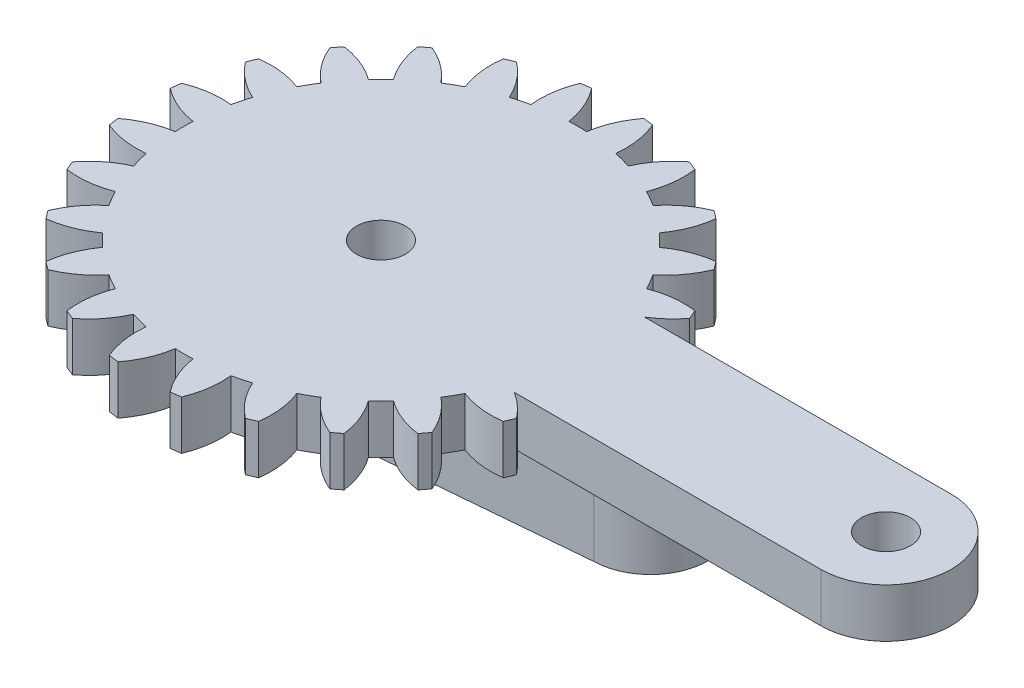
from build123d import *

# Parameters (mm, degrees)
SKETCH1_R           = 1.5
BOSS_EXTRUDE1_DEPTH = 1.5
BOSS_EXTRUDE2_DEPTH = 4


with BuildPart() as part:
    # Sketch1 → Boss-Extrude1 (new body, symmetric)
    with BuildSketch(Plane(origin=(0, 0, 0), x_dir=(1, 0, 0), z_dir=(0, 1, 0))):
        with BuildLine():
            Line((11.067960149, -3.770386358), (29.879975659, -3.770386358))
            ThreePointArc((29.879975659, -3.770386358), (33.879975659, 0.229613642), (29.879975659, 4.229613642))
            Line((29.879975659, 4.229613642), (11.067960149, 4.229613642))
            ThreePointArc((11.067960149, 4.229613642), (11.847346546, 4.817815376), (12.508067649, 5.536753523))
            ThreePointArc((12.508067649, 5.536753523), (12.391713822, 5.826358841), (12.269206518, 6.113415305))
            ThreePointArc((12.269206518, 6.113415305), (10.921594192, 6.123653667), (9.613413173, 5.799884882))
            ThreePointArc((9.613413173, 5.799884882), (9.35260436, 6.275988642), (9.070690816, 6.73990758))
            ThreePointArc((9.070690816, 6.73990758), (10.005173318, 7.710941183), (10.670112799, 8.883126872))
            ThreePointArc((10.670112799, 8.883126872), (10.482768261, 9.132749542), (10.290139612, 9.378317571))
            ThreePointArc((10.290139612, 9.378317571), (8.985796179, 9.039419334), (7.805987876, 8.38810054))
            ThreePointArc((7.805987876, 8.38810054), (7.430841187, 8.780479171), (7.038462557, 9.155625859))
            ThreePointArc((7.038462557, 9.155625859), (7.68978135, 10.335434163), (8.028679587, 11.639777595))
            ThreePointArc((8.028679587, 11.639777595), (7.783111558, 11.832406244), (7.533488888, 12.019750783))
            ThreePointArc((7.533488888, 12.019750783), (6.361303199, 11.354811301), (5.390269597, 10.420328799))
            ThreePointArc((5.390269597, 10.420328799), (4.926350659, 10.702242344), (4.450246898, 10.963051157))
            ThreePointArc((4.450246898, 10.963051157), (4.774015684, 12.271232176), (4.763777322, 13.618844501))
            ThreePointArc((4.763777322, 13.618844501), (4.476720857, 13.741351805), (4.187115539, 13.857705633))
            ThreePointArc((4.187115539, 13.857705633), (3.22697011, 12.912039434), (2.530885544, 11.758076661))
            ThreePointArc((2.530885544, 11.758076661), (2.009809666, 11.910313178), (1.48242646, 12.039010426))
            ThreePointArc((1.48242646, 12.039010426), (1.45658093, 13.386413785), (1.097903696, 14.685457451))
            ThreePointArc((1.097903696, 14.685457451), (0.78892122, 14.72949474), (0.479069377, 14.766928535))
            ThreePointArc((0.479069377, 14.766928535), (-0.203603467, 13.604981207), (-0.577301983, 12.31017882))
            ThreePointArc((-0.577301983, 12.31017882), (-1.120024341, 12.322363642), (-1.662746699, 12.31017882))
            ThreePointArc((-1.662746699, 12.31017882), (-2.036445216, 13.604981207), (-2.71911806, 14.766928535))
            ThreePointArc((-2.71911806, 14.766928535), (-3.028969902, 14.72949474), (-3.337952378, 14.685457451))
            ThreePointArc((-3.337952378, 14.685457451), (-3.696629612, 13.386413785), (-3.722475143, 12.039010426))
            ThreePointArc((-3.722475143, 12.039010426), (-4.249858349, 11.910313178), (-4.770934227, 11.758076661))
            ThreePointArc((-4.770934227, 11.758076661), (-5.467018792, 12.912039434), (-6.427164221, 13.857705633))
            ThreePointArc((-6.427164221, 13.857705633), (-6.71676954, 13.741351805), (-7.003826004, 13.618844501))
            ThreePointArc((-7.003826004, 13.618844501), (-7.014064366, 12.271232176), (-6.690295581, 10.963051157))
            ThreePointArc((-6.690295581, 10.963051157), (-7.166399341, 10.702242344), (-7.630318279, 10.420328799))
            ThreePointArc((-7.630318279, 10.420328799), (-8.601351881, 11.354811301), (-9.773537571, 12.019750783))
            ThreePointArc((-9.773537571, 12.019750783), (-10.02316024, 11.832406244), (-10.26872827, 11.639777595))
            ThreePointArc((-10.26872827, 11.639777595), (-9.929830033, 10.335434163), (-9.278511239, 9.155625859))
            ThreePointArc((-9.278511239, 9.155625859), (-9.670889869, 8.780479171), (-10.046036558, 8.38810054))
            ThreePointArc((-10.046036558, 8.38810054), (-11.225844862, 9.039419334), (-12.530188294, 9.378317571))
            ThreePointArc((-12.530188294, 9.378317571), (-12.722816943, 9.132749542), (-12.910161481, 8.883126872))
            ThreePointArc((-12.910161481, 8.883126872), (-12.245222, 7.710941183), (-11.310739498, 6.73990758))
            ThreePointArc((-11.310739498, 6.73990758), (-11.592653043, 6.275988642), (-11.853461856, 5.799884882))
            ThreePointArc((-11.853461856, 5.799884882), (-13.161642874, 6.123653667), (-14.5092552, 6.113415305))
            ThreePointArc((-14.5092552, 6.113415305), (-14.631762504, 5.826358841), (-14.748116331, 5.536753523))
            ThreePointArc((-14.748116331, 5.536753523), (-13.802450133, 4.576608094), (-12.64848736, 3.880523528))
            ThreePointArc((-12.64848736, 3.880523528), (-12.800723877, 3.35944765), (-12.929421125, 2.832064444))
            ThreePointArc((-12.929421125, 2.832064444), (-14.276824484, 2.806218913), (-15.57586815, 2.44754168))
            ThreePointArc((-15.57586815, 2.44754168), (-15.619905439, 2.138559204), (-15.657339233, 1.828707361))
            ThreePointArc((-15.657339233, 1.828707361), (-14.495391906, 1.146034517), (-13.200589518, 0.772336))
            ThreePointArc((-13.200589518, 0.772336), (-13.212774341, 0.229613642), (-13.200589518, -0.313108715))
            ThreePointArc((-13.200589518, -0.313108715), (-14.495391906, -0.686807232), (-15.657339233, -1.369480076))
            ThreePointArc((-15.657339233, -1.369480076), (-15.619905439, -1.679331919), (-15.57586815, -1.988314395))
            ThreePointArc((-15.57586815, -1.988314395), (-14.276824484, -2.346991628), (-12.929421125, -2.372837159))
            ThreePointArc((-12.929421125, -2.372837159), (-12.800723877, -2.900220365), (-12.64848736, -3.421296243))
            ThreePointArc((-12.64848736, -3.421296243), (-13.802450133, -4.117380809), (-14.748116331, -5.077526238))
            ThreePointArc((-14.748116331, -5.077526238), (-14.631762504, -5.367131556), (-14.5092552, -5.65418802))
            ThreePointArc((-14.5092552, -5.65418802), (-13.161642874, -5.664426382), (-11.853461856, -5.340657597))
            ThreePointArc((-11.853461856, -5.340657597), (-11.592653043, -5.816761358), (-11.310739498, -6.280680295))
            ThreePointArc((-11.310739498, -6.280680295), (-12.245222, -7.251713898), (-12.910161481, -8.423899587))
            ThreePointArc((-12.910161481, -8.423899587), (-12.722816943, -8.673522257), (-12.530188294, -8.919090286))
            ThreePointArc((-12.530188294, -8.919090286), (-11.225844862, -8.580192049), (-10.046036558, -7.928873256))
            ThreePointArc((-10.046036558, -7.928873256), (-9.670889869, -8.321251886), (-9.278511239, -8.696398575))
            ThreePointArc((-9.278511239, -8.696398575), (-9.929830033, -9.876206878), (-10.26872827, -11.18055031))
            ThreePointArc((-10.26872827, -11.18055031), (-10.02316024, -11.373178959), (-9.773537571, -11.560523498))
            ThreePointArc((-9.773537571, -11.560523498), (-8.601351881, -10.895584017), (-7.630318279, -9.961101514))
            ThreePointArc((-7.630318279, -9.961101514), (-7.166399341, -10.243015059), (-6.690295581, -10.503823872))
            ThreePointArc((-6.690295581, -10.503823872), (-7.014064366, -11.812004891), (-7.003826004, -13.159617217))
            ThreePointArc((-7.003826004, -13.159617217), (-6.71676954, -13.282124521), (-6.427164222, -13.398478348))
            ThreePointArc((-6.427164222, -13.398478348), (-5.467018793, -12.452812149), (-4.770934227, -11.298849376))
            ThreePointArc((-4.770934227, -11.298849376), (-4.249858349, -11.451085894), (-3.722475143, -11.579783141))
            ThreePointArc((-3.722475143, -11.579783141), (-3.696629612, -12.9271865), (-3.337952379, -14.226230166))
            ThreePointArc((-3.337952379, -14.226230166), (-3.028969902, -14.270267455), (-2.71911806, -14.30770125))
            ThreePointArc((-2.71911806, -14.30770125), (-2.036445216, -13.145753923), (-1.662746699, -11.850951535))
            ThreePointArc((-1.662746699, -11.850951535), (-1.120024341, -11.863136358), (-0.577301983, -11.850951535))
            ThreePointArc((-0.577301983, -11.850951535), (-0.203603467, -13.145753923), (0.479069377, -14.30770125))
            ThreePointArc((0.479069377, -14.30770125), (0.78892122, -14.270267455), (1.097903696, -14.226230166))
            ThreePointArc((1.097903696, -14.226230166), (1.45658093, -12.9271865), (1.48242646, -11.579783141))
            ThreePointArc((1.48242646, -11.579783141), (2.009809666, -11.451085893), (2.530885544, -11.298849376))
            ThreePointArc((2.530885544, -11.298849376), (3.22697011, -12.452812149), (4.187115539, -13.398478348))
            ThreePointArc((4.187115539, -13.398478348), (4.476720857, -13.282124521), (4.763777322, -13.159617216))
            ThreePointArc((4.763777322, -13.159617216), (4.774015684, -11.812004891), (4.450246898, -10.503823872))
            ThreePointArc((4.450246898, -10.503823872), (4.926350659, -10.243015059), (5.390269597, -9.961101514))
            ThreePointArc((5.390269597, -9.961101514), (6.361303199, -10.895584017), (7.533488888, -11.560523498))
            ThreePointArc((7.533488888, -11.560523498), (7.783111558, -11.373178959), (8.028679587, -11.18055031))
            ThreePointArc((8.028679587, -11.18055031), (7.68978135, -9.876206878), (7.038462557, -8.696398575))
            ThreePointArc((7.038462557, -8.696398575), (7.430841187, -8.321251886), (7.805987876, -7.928873256))
            ThreePointArc((7.805987876, -7.928873256), (8.985796179, -8.580192049), (10.290139612, -8.919090286))
            ThreePointArc((10.290139612, -8.919090286), (10.482768261, -8.673522257), (10.670112799, -8.423899587))
            ThreePointArc((10.670112799, -8.423899587), (10.005173318, -7.251713898), (9.070690816, -6.280680295))
            ThreePointArc((9.070690816, -6.280680295), (9.35260436, -5.816761358), (9.613413173, -5.340657597))
            ThreePointArc((9.613413173, -5.340657597), (10.921594192, -5.664426382), (12.269206518, -5.65418802))
            ThreePointArc((12.269206518, -5.65418802), (12.391713822, -5.367131556), (12.508067649, -5.077526238))
            ThreePointArc((12.508067649, -5.077526238), (11.847346546, -4.358588091), (11.067960149, -3.770386358))
        make_face()
        with Locations((29.879975659, 0.229613642)):
            Circle(SKETCH1_R, mode=Mode.SUBTRACT)
        with Locations((-1.120024341, 0.229613642)):
            Circle(SKETCH1_R, mode=Mode.SUBTRACT)
    extrude(amount=BOSS_EXTRUDE1_DEPTH, both=True)

    # Sketch2 → Boss-Extrude2 (add)
    with BuildSketch(Plane.XZ.offset(1.5)):
        with BuildLine():
            Line((-0.313290616, 4.715007748), (15.495042643, 3.3195926))
            ThreePointArc((15.495042643, 3.3195926), (18.969975659, -0.229613642), (15.495042643, -3.778819884))
            Line((15.495042643, -3.778819884), (-0.313290616, -5.174235033))
            ThreePointArc((-0.313290616, -5.174235033), (-6.130024341, -0.229613642), (-0.313290616, 4.715007748))
        make_face()
        with BuildLine():
            Line((-0.505153828, 3.22611121), (15.419975659, 1.820386358))
            ThreePointArc((15.419975659, 1.820386358), (17.469975659, -0.229613642), (15.419975659, -2.279613642))
            Line((15.419975659, -2.279613642), (-0.505153828, -3.685338494))
            ThreePointArc((-0.505153828, -3.685338494), (-4.630024341, -0.229613642), (-0.505153828, 3.22611121))
        make_face(mode=Mode.SUBTRACT)
    extrude(amount=BOSS_EXTRUDE2_DEPTH)


solid = part.part
